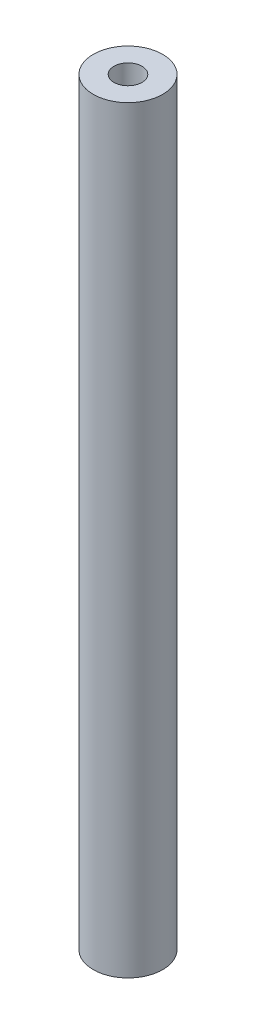
from build123d import *

# Parameters (mm, degrees)
SKETCH1_R                                = 5
BOSS_EXTRUDE2_DEPTH                      = 109.22
CUT_EXTRUDE1_DEPTH                       = 2.54
TAP_DRILL_FOR_10_32_TAP1_D               = 4.0386
TAP_DRILL_FOR_10_32_TAP1_DEPTH           = 11.486682152
TAP_DRILL_FOR_10_32_TAP1_TIP             = 1.213317848
TAP_DRILL_FOR_10_32_TAP1_ON_FACE_2_D     = 4.0386
TAP_DRILL_FOR_10_32_TAP1_ON_FACE_2_DEPTH = 11.486682152
TAP_DRILL_FOR_10_32_TAP1_ON_FACE_2_TIP   = 1.213317848


with BuildPart() as part:
    # Sketch1 → Boss-Extrude2 (new body)
    with BuildSketch(Plane(origin=(0, 0, 0), x_dir=(1, 0, 0), z_dir=(0, 1, 0))):
        Circle(SKETCH1_R)
    extrude(amount=-BOSS_EXTRUDE2_DEPTH)

    # Sketch2 → Cut-Extrude1 (cut)
    with BuildSketch(Plane(origin=(0, 0, -5), x_dir=(-1, 0, 0), z_dir=(0, 0, -1))):
        with BuildLine():
            Line((-2, -109.22), (-2, -114.22))
            ThreePointArc((-2, -114.22), (0, -116.22), (2, -114.22))
            Line((2, -114.22), (2, -109.22))
            ThreePointArc((2, -109.22), (0, -107.22), (-2, -109.22))
        make_face()
        with BuildLine():
            Line((-1.5, -63.5), (-1.5, -68.5))
            ThreePointArc((-1.5, -68.5), (0, -70), (1.5, -68.5))
            Line((1.5, -68.5), (1.5, -63.5))
            ThreePointArc((1.5, -63.5), (0, -62), (-1.5, -63.5))
        make_face()
        with BuildLine():
            Line((-1.5, -10.39), (-1.5, -15.39))
            ThreePointArc((-1.5, -15.39), (0, -16.89), (1.5, -15.39))
            Line((1.5, -15.39), (1.5, -10.39))
            ThreePointArc((1.5, -10.39), (0, -8.89), (-1.5, -10.39))
        make_face()
    extrude(amount=-CUT_EXTRUDE1_DEPTH, mode=Mode.SUBTRACT)

    # Tap Drill for #10-32 Tap1
    with Locations(Plane.ZX):
        with Locations((0, 0)):
            Hole(TAP_DRILL_FOR_10_32_TAP1_D / 2, depth=TAP_DRILL_FOR_10_32_TAP1_DEPTH)
            with Locations((0, 0, -(TAP_DRILL_FOR_10_32_TAP1_DEPTH + TAP_DRILL_FOR_10_32_TAP1_TIP / 2))):  # 118° drill point
                Cone(0, TAP_DRILL_FOR_10_32_TAP1_D / 2, TAP_DRILL_FOR_10_32_TAP1_TIP, mode=Mode.SUBTRACT)

    # Tap Drill for #10-32 Tap1 on face 2
    with Locations(Plane(origin=(0, -109.22, 0), x_dir=(0, 0, -1), z_dir=(0, -1, 0))):
        with Locations((0, 0)):
            Hole(TAP_DRILL_FOR_10_32_TAP1_ON_FACE_2_D / 2, depth=TAP_DRILL_FOR_10_32_TAP1_ON_FACE_2_DEPTH)
            with Locations((0, 0, -(TAP_DRILL_FOR_10_32_TAP1_ON_FACE_2_DEPTH + TAP_DRILL_FOR_10_32_TAP1_ON_FACE_2_TIP / 2))):  # 118° drill point
                Cone(0, TAP_DRILL_FOR_10_32_TAP1_ON_FACE_2_D / 2, TAP_DRILL_FOR_10_32_TAP1_ON_FACE_2_TIP, mode=Mode.SUBTRACT)


solid = part.part
